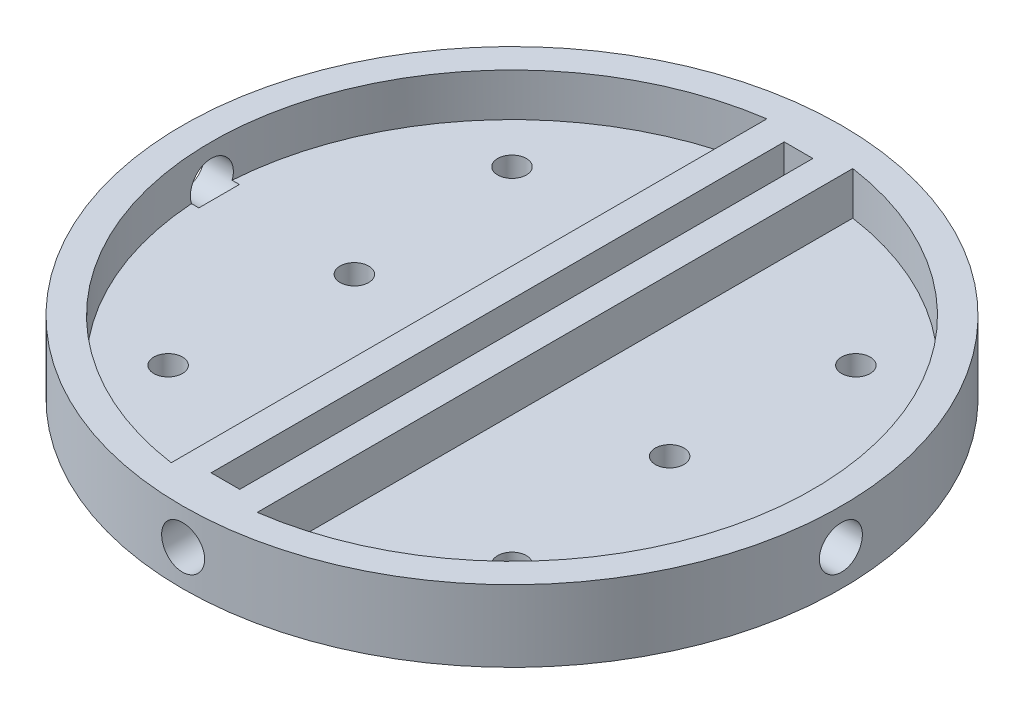
from build123d import *

# Parameters (mm, degrees)
SKETCH5_R           = 73.025
SKETCH5_R_2         = 3.175
PLATEBASE_DEPTH     = 6.35
PLATETOP_DEPTH      = 9.525
SKETCH9_R           = 73.025
SKETCH9_R_2         = 66.675
PLATEWALLS_DEPTH    = 9.525
SKETCH13_R          = 3.175
RIGHTTHRUHOLE_DEPTH = 6.35
SKETCH14_R          = 3.175
LEFTTHRUHOLE_DEPTH  = 6.35
BOSS_EXTRUDE1_DEPTH = 9.525
SKETCH16_R          = 4.765
INSERTHOLE_DEPTH    = 8.128
INSERTHOLES_COUNT   = 4


with BuildPart() as part:
    # Sketch5 → PlateBase (new body)
    with BuildSketch(Plane(origin=(0, 0, 0), x_dir=(1, 0, 0), z_dir=(0, 1, 0))):
        Circle(SKETCH5_R)
        with Locations((38.1, 38.1)):
            Circle(SKETCH5_R_2, mode=Mode.SUBTRACT)
        with Locations((38.1, -38.1)):
            Circle(SKETCH5_R_2, mode=Mode.SUBTRACT)
        with Locations((-38.1, 38.1)):
            Circle(SKETCH5_R_2, mode=Mode.SUBTRACT)
        with Locations((-38.1, -38.1)):
            Circle(SKETCH5_R_2, mode=Mode.SUBTRACT)
    extrude(amount=PLATEBASE_DEPTH)

    # Sketch6 → PlateTop (add)
    with BuildSketch(Plane(origin=(0, 6.35, 0), x_dir=(1, 0, 0), z_dir=(0, 1, 0))):
        with BuildLine():
            Line((-3.175, 0), (-3.175, 72.955945611))
            ThreePointArc((-3.175, 72.955945611), (-6.35605636, 72.747860261), (-9.525, 72.401139494))
            Line((-9.525, 72.401139494), (-9.525, 0))
            Line((-9.525, 0), (-9.525, -72.401139494))
            ThreePointArc((-9.525, -72.401139494), (-6.35605636, -72.747860261), (-3.175, -72.955945611))
            Line((-3.175, -72.955945611), (-3.175, 0))
        make_face()
        with BuildLine():
            Line((3.175, 72.955945611), (3.175, 0))
            Line((3.175, 0), (3.175, -72.955945611))
            ThreePointArc((3.175, -72.955945611), (6.35605636, -72.747860261), (9.525, -72.401139494))
            Line((9.525, -72.401139494), (9.525, 0))
            Line((9.525, 0), (9.525, 72.401139494))
            ThreePointArc((9.525, 72.401139494), (6.35605636, 72.747860261), (3.175, 72.955945611))
        make_face()
    extrude(amount=PLATETOP_DEPTH)

    # Sketch9 → PlateWalls (add)
    with BuildSketch(Plane(origin=(0, 6.35, 0), x_dir=(1, 0, 0), z_dir=(0, 1, 0))):
        Circle(SKETCH9_R)
        Circle(SKETCH9_R_2, mode=Mode.SUBTRACT)
    extrude(amount=PLATEWALLS_DEPTH)

    # Sketch13 → RightThruHole (cut)
    with BuildSketch(Plane(origin=(0, 6.35, 0), x_dir=(1, 0, 0), z_dir=(0, 1, 0))):
        with Locations((34.925, 0)):
            Circle(SKETCH13_R)
    extrude(amount=-RIGHTTHRUHOLE_DEPTH, mode=Mode.SUBTRACT)

    # Sketch14 → LeftThruHole (cut)
    with BuildSketch(Plane(origin=(0, 6.35, 0), x_dir=(1, 0, 0), z_dir=(0, 1, 0))):
        with Locations((-34.925, 0)):
            Circle(SKETCH14_R)
    extrude(amount=-LEFTTHRUHOLE_DEPTH, mode=Mode.SUBTRACT)

    # Sketch15 → Boss-Extrude1 (add)
    with BuildSketch(Plane(origin=(0, 6.35, 0), x_dir=(1, 0, 0), z_dir=(0, 1, 0))):
        with BuildLine():
            Line((-3.175, 63.5), (3.175, 63.5))
            Line((3.175, 63.5), (3.175, 66.599361859))
            ThreePointArc((3.175, 66.599361859), (0, 66.675), (-3.175, 66.599361859))
            Line((-3.175, 66.599361859), (-3.175, 63.5))
        make_face()
        with BuildLine():
            Line((-3.175, -63.5), (-3.175, -66.599361859))
            ThreePointArc((-3.175, -66.599361859), (0, -66.675), (3.175, -66.599361859))
            Line((3.175, -66.599361859), (3.175, -63.5))
            Line((3.175, -63.5), (-3.175, -63.5))
        make_face()
    extrude(amount=BOSS_EXTRUDE1_DEPTH)

    # Sketch16 → InsertHole (cut)
    with BuildSketch(Plane.XY.offset(73.025)):
        with Locations((0, 7.9375)):
            Circle(SKETCH16_R)
    inserthole = extrude(amount=-INSERTHOLE_DEPTH, mode=Mode.SUBTRACT)

    # InsertHoles: InsertHole ×4 about axis
    insertholes_axis = Axis((0, 0, 0), (0, 1, 0))
    for i in range(1, INSERTHOLES_COUNT):
        add(inserthole.rotate(insertholes_axis, i * 360 / INSERTHOLES_COUNT), mode=Mode.SUBTRACT)


solid = part.part
